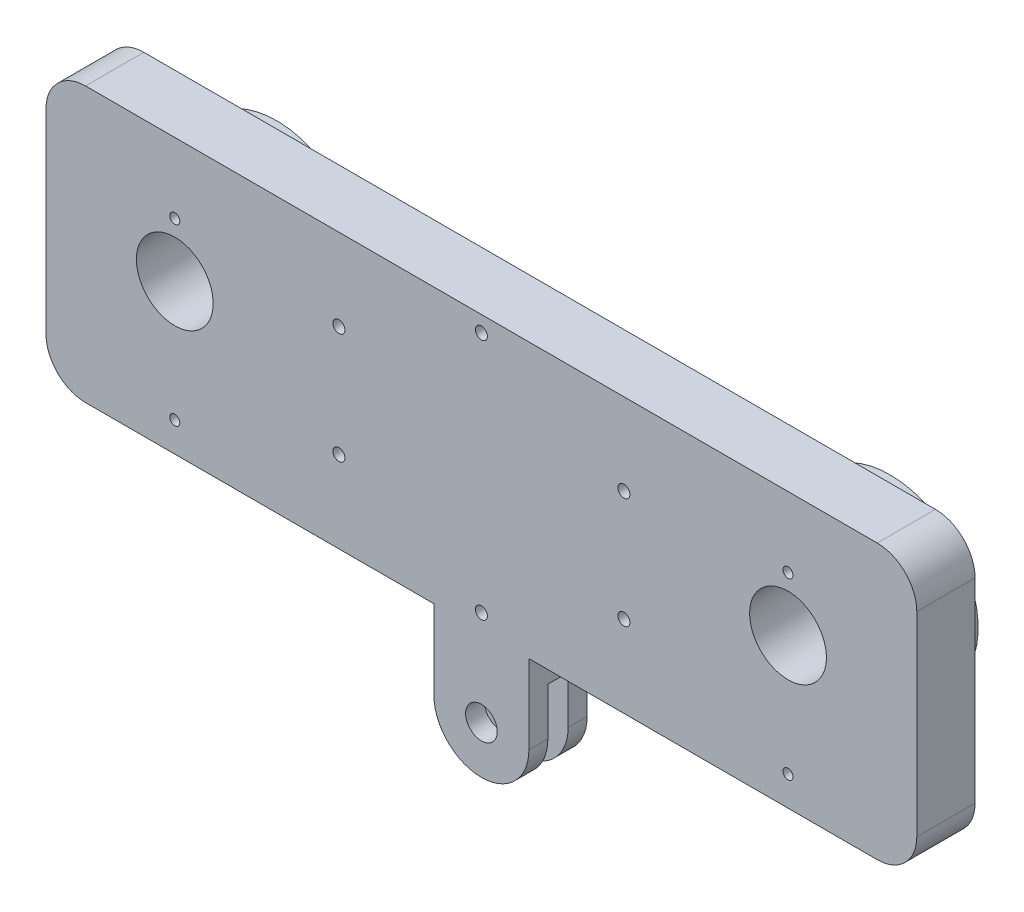
from build123d import *

# Parameters (mm, degrees)
BOSS_EXTRUDE1_DEPTH = 15.24
CUT_EXTRUDE1_DEPTH  = 24.492240162
SKETCH3_W           = 139.7
SKETCH3_H           = 44
BOSS_EXTRUDE2_DEPTH = 9.3472
FILLET1_R           = 6.35
SKETCH7_R           = 6.1595
CUT_EXTRUDE2_DEPTH  = 93.183607262
SKETCH6_R           = 0.9652
CUT_EXTRUDE3_DEPTH  = 5.588
SKETCH8_R           = 0.80645
CUT_EXTRUDE4_DEPTH  = 5.08
SKETCH9_R           = 14.175
SKETCH9_R_2         = 11
BOSS_EXTRUDE5_DEPTH = 6.985
FILLET2_R           = 2.54


with BuildPart() as part:
    # Sketch1 → Boss-Extrude1 (new body)
    with BuildSketch(Plane(origin=(0, 0, 0), x_dir=(0, 0, -1), z_dir=(1, 0, 0))):
        Polygon((-4.6736, 0), (-4.6736, 5.08), (4.6736, 5.08), (4.6736, 0), (4.6736, -15.24), (1.6256, -15.24), (1.6256, 0), (-1.6256, 0), (-1.6256, -15.24), (-4.6736, -15.24), align=None)
    extrude(amount=-BOSS_EXTRUDE1_DEPTH)

    # Sketch2 → Cut-Extrude1 (cut, through all)
    with BuildSketch(Plane.XY.offset(4.6736)):
        with BuildLine():
            ThreePointArc((-5.08, -7.62), (-5.823948776, -5.823948776), (-7.62, -5.08))
            Line((-7.62, -5.08), (-7.62, -10.16))
            ThreePointArc((-7.62, -10.16), (-5.823948776, -9.416051224), (-5.08, -7.62))
        make_face()
        with BuildLine():
            Line((-7.62, -10.16), (-7.62, -5.08))
            ThreePointArc((-7.62, -5.08), (-10.16, -7.62), (-7.62, -10.16))
        make_face()
        with BuildLine():
            ThreePointArc((-7.62, -15.24), (-13.008153673, -13.008153673), (-15.24, -7.62))
            Line((-15.24, -7.62), (-15.24, -15.24))
            Line((-15.24, -15.24), (-7.62, -15.24))
        make_face()
        with BuildLine():
            Line((0, -15.24), (0, -7.62))
            ThreePointArc((0, -7.62), (-2.231846327, -13.008153673), (-7.62, -15.24))
            Line((-7.62, -15.24), (0, -15.24))
        make_face()
    extrude(amount=-CUT_EXTRUDE1_DEPTH, mode=Mode.SUBTRACT)

    # Sketch3 → Boss-Extrude2 (add)
    with BuildSketch(Plane.XY.offset(4.6736)):
        with Locations((-7.62, 27.08)):
            Rectangle(SKETCH3_W, SKETCH3_H)
    extrude(amount=-BOSS_EXTRUDE2_DEPTH)

    # Fillet1
    fillet1_edges = [part.edges().sort_by_distance(p)[0] for p in [
        (62.23, 5.08, 0),
        (62.23, 49.08, 0),
        (-77.47, 49.08, 0),
        (-77.47, 5.08, 0),
    ]]
    fillet(fillet1_edges, radius=FILLET1_R)

    # Sketch7 → Cut-Extrude2 (cut, through all)
    with BuildSketch(Plane(origin=(0, 0, -4.6736), x_dir=(-1, 0, 0), z_dir=(0, 0, -1))):
        with Locations((-41.57, 29.08)):
            Circle(SKETCH7_R)
        with Locations((56.81, 29.08)):
            Circle(SKETCH7_R)
    extrude(amount=-CUT_EXTRUDE2_DEPTH, mode=Mode.SUBTRACT)

    # Sketch6 → Cut-Extrude3 (cut)
    with BuildSketch(Plane.XY.offset(4.6736)):
        with Locations((-30.48, 35.97)):
            Circle(SKETCH6_R)
        with Locations((-30.48, 18.19)):
            Circle(SKETCH6_R)
        with Locations((15.24, 35.97)):
            Circle(SKETCH6_R)
        with Locations((15.24, 18.19)):
            Circle(SKETCH6_R)
        with Locations((-7.62, 46.511)):
            Circle(SKETCH6_R)
        with Locations((-7.62, 7.649)):
            Circle(SKETCH6_R)
    extrude(amount=-CUT_EXTRUDE3_DEPTH, mode=Mode.SUBTRACT)

    # Sketch8 → Cut-Extrude4 (cut)
    with BuildSketch(Plane.XY.offset(4.6736)):
        with Locations((-56.81, 9.83)):
            Circle(SKETCH8_R)
        with Locations((-56.81, 37.83)):
            Circle(SKETCH8_R)
        with Locations((41.57, 9.83)):
            Circle(SKETCH8_R)
        with Locations((41.57, 37.83)):
            Circle(SKETCH8_R)
    extrude(amount=-CUT_EXTRUDE4_DEPTH, mode=Mode.SUBTRACT)

    # Sketch9 → Boss-Extrude5 (add)
    with BuildSketch(Plane(origin=(0, 0, -4.6736), x_dir=(-1, 0, 0), z_dir=(0, 0, -1))):
        with Locations((-41.57, 29.08)):
            Circle(SKETCH9_R)
        with Locations((-41.57, 29.08)):
            Circle(SKETCH9_R_2, mode=Mode.SUBTRACT)
        with Locations((56.81, 29.08)):
            Circle(SKETCH9_R)
        with Locations((56.81, 29.08)):
            Circle(SKETCH9_R_2, mode=Mode.SUBTRACT)
    extrude(amount=BOSS_EXTRUDE5_DEPTH)

    # Fillet2
    fillet2_edges = [part.edges().sort_by_distance(p)[0] for p in [
        (55.745, 29.08, -4.6736),
        (-42.635, 29.08, -4.6736),
    ]]
    fillet(fillet2_edges, radius=FILLET2_R)


solid = part.part
